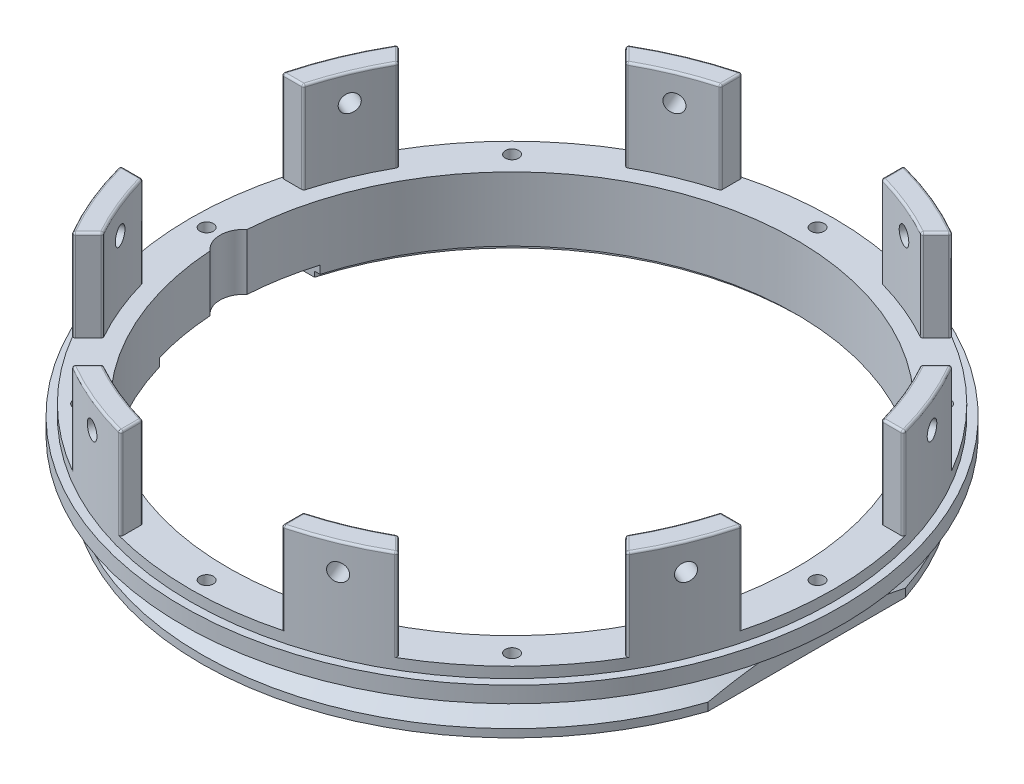
from build123d import *

# Parameters (mm, degrees)
SKIZZE2_W                       = 30
SKIZZE2_H                       = 17
SCHNITT_LINEAR_AUSTRAGEN1_DEPTH = 62.5
KREISMUSTER1_COUNT              = 8
SKIZZE3_R                       = 1.65
SCHNITT_LINEAR_AUSTRAGEN2_DEPTH = 25.76666665
KREISMUSTER2_COUNT              = 8
SCHNITT_LINEAR_AUSTRAGEN3_REACH = 15
SKIZZE4_R                       = 1.25
SCHNITT_LINEAR_AUSTRAGEN4_REACH = 32
SKIZZE5_W                       = 3
SKIZZE5_H                       = 36.82390528
SKIZZE6_W                       = 7.166939891
SKIZZE6_H                       = 30
SCHNITT_LINEAR_AUSTRAGEN5_DEPTH = 2.5
SCHNITT_LINEAR_AUSTRAGEN6_REACH = 15
SKIZZE7_R                       = 4.5
VERRUNDUNG1_R                   = 0.2
VERRUNDUNG2_R                   = 0.4


with BuildPart() as part:
    # Skizze1 → Rotation1 (revolve)
    with BuildSketch(Plane.XY):
        Polygon((-53, 1), (-53, 13), (-56, 13), (-56, 30), (-60, 30), (-60, 11), (-61.5, 11), (-61.5, 8), (-55, 8), (-55, 3.600622615), (-58, 1.5), (-58, 0), (-54, 0), (-54, 1), align=None)
    revolve(axis=Axis((0, 0, 0), (0, 1, 0)))

    # Skizze2 → Schnitt-Linear austragen1 (cut, symmetric)
    with BuildSketch(Plane(origin=(0, 0, 0), x_dir=(0, 0, -1), z_dir=(1, 0, 0))):
        with Locations((0, 21.5)):
            Rectangle(SKIZZE2_W, SKIZZE2_H)
    schnitt_linear_austragen1 = extrude(amount=SCHNITT_LINEAR_AUSTRAGEN1_DEPTH, both=True, mode=Mode.SUBTRACT)

    # Kreismuster1: Schnitt-Linear austragen1 ×8 about axis
    kreismuster1_axis = Axis((0, 0, 0), (0, 1, 0))
    for i in range(1, KREISMUSTER1_COUNT):
        add(schnitt_linear_austragen1.rotate(kreismuster1_axis, i * 360 / KREISMUSTER1_COUNT), mode=Mode.SUBTRACT)

    # Skizze3 → Schnitt-Linear austragen2 (cut, through all)
    with BuildSketch(Plane(origin=(-51.355650636, 0, 21.272206998), x_dir=(-0.382683432, 0, -0.923879533), z_dir=(0.923879533, 0, -0.382683432))):
        with Locations((0, 25)):
            Circle(SKIZZE3_R)
    schnitt_linear_austragen2 = extrude(amount=-SCHNITT_LINEAR_AUSTRAGEN2_DEPTH, mode=Mode.SUBTRACT)

    # Kreismuster2: Schnitt-Linear austragen2 ×8 about axis
    kreismuster2_axis = Axis((0, 0, 0), (0, -1, 0))
    for i in range(1, KREISMUSTER2_COUNT):
        add(schnitt_linear_austragen2.rotate(kreismuster2_axis, i * 360 / KREISMUSTER2_COUNT), mode=Mode.SUBTRACT)

    # Skizze4 → Schnitt-Linear austragen3 (cut, up to next)
    with BuildSketch(Plane(origin=(0, 13, 0), x_dir=(1, 0, 0), z_dir=(0, 1, 0)), mode=Mode.PRIVATE) as schnitt_linear_austragen3_sk1:
        with Locations((0, 57)):
            Circle(SKIZZE4_R)
    schnitt_linear_austragen3_tool1 = extrude(schnitt_linear_austragen3_sk1.sketch, amount=-SCHNITT_LINEAR_AUSTRAGEN3_REACH, mode=Mode.PRIVATE) & part.part
    add(schnitt_linear_austragen3_tool1.solids().sort_by_distance((0, 13, -57))[0], mode=Mode.SUBTRACT)
    # Skizze4 → Schnitt-Linear austragen3 (cut, up to next)
    with BuildSketch(Plane(origin=(0, 13, 0), x_dir=(1, 0, 0), z_dir=(0, 1, 0)), mode=Mode.PRIVATE) as schnitt_linear_austragen3_sk2:
        with Locations((40.305086528, 40.305086528)):
            Circle(SKIZZE4_R)
    schnitt_linear_austragen3_tool2 = extrude(schnitt_linear_austragen3_sk2.sketch, amount=-SCHNITT_LINEAR_AUSTRAGEN3_REACH, mode=Mode.PRIVATE) & part.part
    add(schnitt_linear_austragen3_tool2.solids().sort_by_distance((40.305087, 13, -40.305087))[0], mode=Mode.SUBTRACT)
    # Skizze4 → Schnitt-Linear austragen3 (cut, up to next)
    with BuildSketch(Plane(origin=(0, 13, 0), x_dir=(1, 0, 0), z_dir=(0, 1, 0)), mode=Mode.PRIVATE) as schnitt_linear_austragen3_sk3:
        with Locations((57, 0)):
            Circle(SKIZZE4_R)
    schnitt_linear_austragen3_tool3 = extrude(schnitt_linear_austragen3_sk3.sketch, amount=-SCHNITT_LINEAR_AUSTRAGEN3_REACH, mode=Mode.PRIVATE) & part.part
    add(schnitt_linear_austragen3_tool3.solids().sort_by_distance((57, 13, 0))[0], mode=Mode.SUBTRACT)
    # Skizze4 → Schnitt-Linear austragen3 (cut, up to next)
    with BuildSketch(Plane(origin=(0, 13, 0), x_dir=(1, 0, 0), z_dir=(0, 1, 0)), mode=Mode.PRIVATE) as schnitt_linear_austragen3_sk4:
        with Locations((40.305086528, -40.305086528)):
            Circle(SKIZZE4_R)
    schnitt_linear_austragen3_tool4 = extrude(schnitt_linear_austragen3_sk4.sketch, amount=-SCHNITT_LINEAR_AUSTRAGEN3_REACH, mode=Mode.PRIVATE) & part.part
    add(schnitt_linear_austragen3_tool4.solids().sort_by_distance((40.305087, 13, 40.305087))[0], mode=Mode.SUBTRACT)
    # Skizze4 → Schnitt-Linear austragen3 (cut, up to next)
    with BuildSketch(Plane(origin=(0, 13, 0), x_dir=(1, 0, 0), z_dir=(0, 1, 0)), mode=Mode.PRIVATE) as schnitt_linear_austragen3_sk5:
        with Locations((0, -57)):
            Circle(SKIZZE4_R)
    schnitt_linear_austragen3_tool5 = extrude(schnitt_linear_austragen3_sk5.sketch, amount=-SCHNITT_LINEAR_AUSTRAGEN3_REACH, mode=Mode.PRIVATE) & part.part
    add(schnitt_linear_austragen3_tool5.solids().sort_by_distance((0, 13, 57))[0], mode=Mode.SUBTRACT)
    # Skizze4 → Schnitt-Linear austragen3 (cut, up to next)
    with BuildSketch(Plane(origin=(0, 13, 0), x_dir=(1, 0, 0), z_dir=(0, 1, 0)), mode=Mode.PRIVATE) as schnitt_linear_austragen3_sk6:
        with Locations((-40.305086528, -40.305086528)):
            Circle(SKIZZE4_R)
    schnitt_linear_austragen3_tool6 = extrude(schnitt_linear_austragen3_sk6.sketch, amount=-SCHNITT_LINEAR_AUSTRAGEN3_REACH, mode=Mode.PRIVATE) & part.part
    add(schnitt_linear_austragen3_tool6.solids().sort_by_distance((-40.305087, 13, 40.305087))[0], mode=Mode.SUBTRACT)
    # Skizze4 → Schnitt-Linear austragen3 (cut, up to next)
    with BuildSketch(Plane(origin=(0, 13, 0), x_dir=(1, 0, 0), z_dir=(0, 1, 0)), mode=Mode.PRIVATE) as schnitt_linear_austragen3_sk7:
        with Locations((-57, 0)):
            Circle(SKIZZE4_R)
    schnitt_linear_austragen3_tool7 = extrude(schnitt_linear_austragen3_sk7.sketch, amount=-SCHNITT_LINEAR_AUSTRAGEN3_REACH, mode=Mode.PRIVATE) & part.part
    add(schnitt_linear_austragen3_tool7.solids().sort_by_distance((-57, 13, 0))[0], mode=Mode.SUBTRACT)
    # Skizze4 → Schnitt-Linear austragen3 (cut, up to next)
    with BuildSketch(Plane(origin=(0, 13, 0), x_dir=(1, 0, 0), z_dir=(0, 1, 0)), mode=Mode.PRIVATE) as schnitt_linear_austragen3_sk8:
        with Locations((-40.305086528, 40.305086528)):
            Circle(SKIZZE4_R)
    schnitt_linear_austragen3_tool8 = extrude(schnitt_linear_austragen3_sk8.sketch, amount=-SCHNITT_LINEAR_AUSTRAGEN3_REACH, mode=Mode.PRIVATE) & part.part
    add(schnitt_linear_austragen3_tool8.solids().sort_by_distance((-40.305087, 13, -40.305087))[0], mode=Mode.SUBTRACT)

    # Skizze5 → Schnitt-Linear austragen4 (cut, up to next)
    with BuildSketch(Plane.XZ, mode=Mode.PRIVATE) as schnitt_linear_austragen4_sk1:
        with Locations((56.5, 0)):
            Rectangle(SKIZZE5_W, SKIZZE5_H)
    schnitt_linear_austragen4_tool1 = extrude(schnitt_linear_austragen4_sk1.sketch, amount=-SCHNITT_LINEAR_AUSTRAGEN4_REACH, mode=Mode.PRIVATE) & part.part
    add(schnitt_linear_austragen4_tool1.solids().sort_by_distance((56.5, 0, 0))[0], mode=Mode.SUBTRACT)

    # Skizze6 → Schnitt-Linear austragen5 (cut)
    with BuildSketch(Plane.XZ):
        with Locations((-54.416530055, 0)):
            Rectangle(SKIZZE6_W, SKIZZE6_H)
    extrude(amount=-SCHNITT_LINEAR_AUSTRAGEN5_DEPTH, mode=Mode.SUBTRACT)

    # Skizze7 → Schnitt-Linear austragen6 (cut, up to next)
    with BuildSketch(Plane(origin=(0, 13, 0), x_dir=(1, 0, 0), z_dir=(0, 1, 0)), mode=Mode.PRIVATE) as schnitt_linear_austragen6_sk1:
        with Locations((-50, 0)):
            Circle(SKIZZE7_R)
    schnitt_linear_austragen6_tool1 = extrude(schnitt_linear_austragen6_sk1.sketch, amount=-SCHNITT_LINEAR_AUSTRAGEN6_REACH, mode=Mode.PRIVATE) & part.part
    add(schnitt_linear_austragen6_tool1.solids().sort_by_distance((-50, 13, 0))[0], mode=Mode.SUBTRACT)

    # Verrundung1
    verrundung1_edges = [part.edges().sort_by_distance(p)[0] for p in [
        (-56.063351883, 2.5, -7.568025737),
    ]]
    fillet(verrundung1_edges, radius=VERRUNDUNG1_R)

    # Verrundung2
    verrundung2_edges = [part.edges().sort_by_distance(p)[0] for p in [
        (-21.430272212, 30, -51.737253821),
        (21.430272212, 30, -51.737253821),
        (51.737253821, 30, -21.430272212),
        (-29.008502046, 30, -50.221705481),
        (-27.544413996, 21.5, -48.757617432),
        (27.544413996, 21.5, 48.757617432),
        (48.757617432, 21.5, 27.544413996),
        (50.221705481, 30, 29.008502046),
        (-48.757617432, 21.5, -27.544413996),
        (-15, 21.5, 53.953683841),
        (-27.544413996, 21.5, 48.757617432),
        (-29.008502046, 30, 50.221705481),
        (-48.757617432, 21.5, 27.544413996),
        (15, 21.5, 53.953683841),
        (15, 30, 56.024217017),
        (15, 30, -56.024217017),
        (15, 21.5, -53.953683841),
        (-15, 21.5, -53.953683841),
        (50.221705481, 30, -29.008502046),
        (48.757617432, 21.5, -27.544413996),
        (27.544413996, 21.5, -48.757617432),
        (-50.221705481, 30, -29.008502046),
        (-15, 30, -56.024217017),
        (29.008502046, 30, -50.221705481),
        (-50.221705481, 30, 29.008502046),
        (29.008502046, 30, 50.221705481),
        (-15, 30, 56.024217017),
        (55.432771951, 30, 22.961005942),
        (-55.432771951, 30, -22.961005942),
        (58.094750193, 21.5, 15),
        (58.094750193, 21.5, -15),
        (-58.094750193, 21.5, 15),
        (-58.094750193, 21.5, -15),
        (51.737253821, 30, 21.430272212),
        (-51.737253821, 30, -21.430272212),
        (53.953683841, 21.5, -15),
        (56.024217017, 30, -15),
        (-56.024217017, 30, -15),
        (-53.953683841, 21.5, -15),
        (-53.953683841, 21.5, 15),
        (53.953683841, 21.5, 15),
        (-56.024217017, 30, 15),
        (56.024217017, 30, 15),
        (-22.961005942, 30, -55.432771951),
        (22.961005942, 30, -55.432771951),
        (55.432771951, 30, -22.961005942),
        (22.961005942, 30, 55.432771951),
        (-22.961005942, 30, 55.432771951),
        (-55.432771951, 30, 22.961005942),
        (30.472590095, 21.5, -51.685793531),
        (51.685793531, 21.5, -30.472590095),
        (-15, 21.5, -58.094750193),
        (15, 21.5, -58.094750193),
        (15, 21.5, 58.094750193),
        (-15, 21.5, 58.094750193),
        (-51.685793531, 21.5, 30.472590095),
        (-30.472590095, 21.5, 51.685793531),
        (-51.685793531, 21.5, -30.472590095),
        (-30.472590095, 21.5, -51.685793531),
        (51.685793531, 21.5, 30.472590095),
        (30.472590095, 21.5, 51.685793531),
        (21.430272212, 30, 51.737253821),
        (-21.430272212, 30, 51.737253821),
        (-51.737253821, 30, 21.430272212),
    ]]
    fillet(verrundung2_edges, radius=VERRUNDUNG2_R)


solid = part.part
